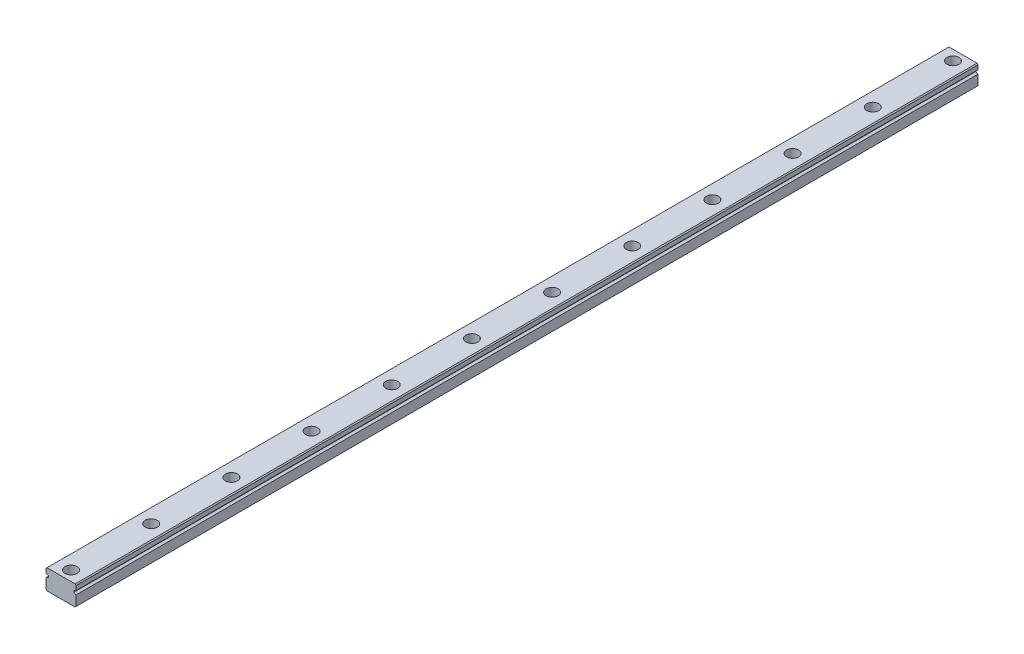
from build123d import *

# Parameters (mm, degrees)
EXTRUDE_1_DEPTH           = 450
HOLE_WIZARD_1_D           = 3.2
HOLE_WIZARD_1_CBORE_D     = 6
HOLE_WIZARD_1_CBORE_DEPTH = 4.5


with BuildPart() as part:
    # 草图1 → 凸台-拉伸1 (new body)
    with BuildSketch(Plane.XY):
        Polygon((-3.269035533, 4.949238579), (10.730964467, 4.949238579), (11.230964467, 4.449238579), (11.230964467, 2.317517259), (10.086764657, 1.783377919), (10.086764657, 0.983377919), (11.230964467, 0.449238579), (11.230964467, -4.550761421), (10.730964467, -5.050761421), (-3.269035533, -5.050761421), (-3.769035533, -4.550761421), (-3.769035533, 0.449238579), (-2.624835723, 0.983377919), (-2.624835723, 1.783377919), (-3.769035533, 2.317517259), (-3.769035533, 4.449238579), align=None)
    extrude(amount=-EXTRUDE_1_DEPTH)

    # 孔1 (through all)
    with Locations(Plane(origin=(3.730964467, 4.949238579, -445), x_dir=(0, 0, 1), z_dir=(0, 1, 0))):
        with Locations((0, 0), (40, 0), (80, 0), (120, 0), (160, 0), (200, 0), (240, 0), (280, 0), (320, 0), (360, 0), (400, 0), (440, 0)):
            CounterBoreHole(HOLE_WIZARD_1_D / 2, HOLE_WIZARD_1_CBORE_D / 2, HOLE_WIZARD_1_CBORE_DEPTH)


solid = part.part
